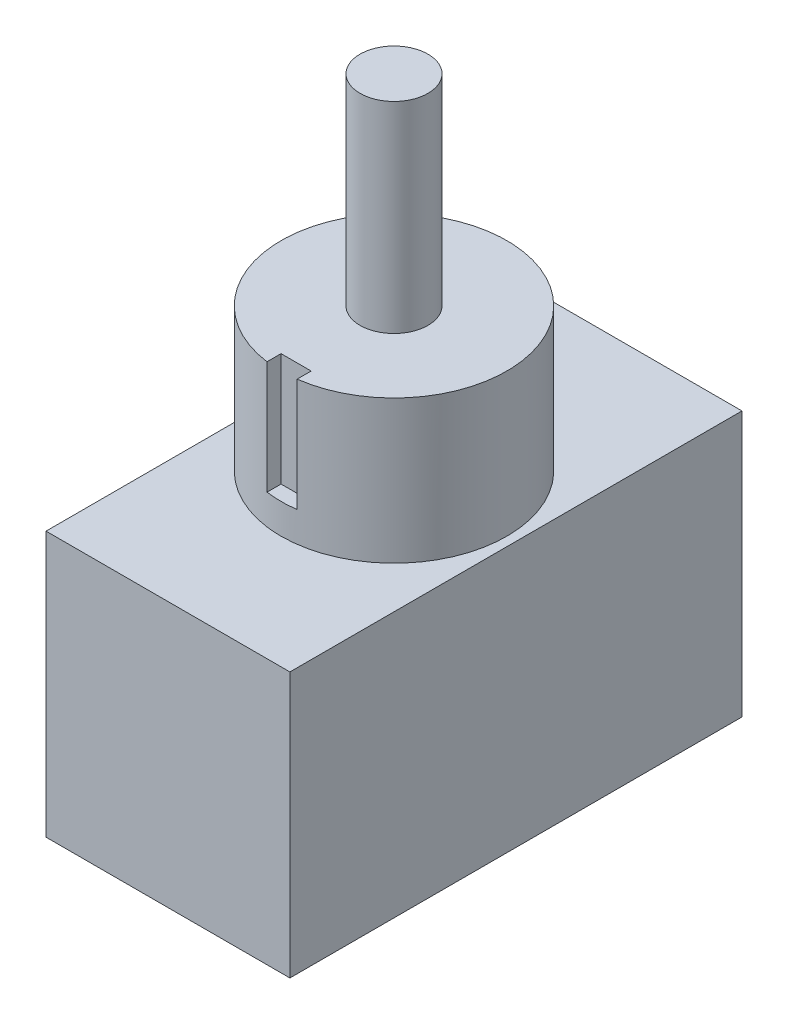
from build123d import *

# Parameters (mm, degrees)
SKETCH1_W           = 12.8524
SKETCH1_H           = 23.8252
BOSS_EXTRUDE1_DEPTH = 13.97
SKETCH2_R           = 5.953125
BOSS_EXTRUDE2_DEPTH = 7.540625
SKETCH3_W           = 1.5875
SKETCH3_H           = 0.79375
CUT_EXTRUDE1_DEPTH  = 5.953125
SKETCH4_R           = 1.790559095
BOSS_EXTRUDE3_DEPTH = 10.5918


with BuildPart() as part:
    # Sketch1 → Boss-Extrude1 (new body)
    with BuildSketch(Plane(origin=(0, 0, 0), x_dir=(1, 0, 0), z_dir=(0, 1, 0))):
        with Locations((-8.41333272, -1.665416216)):
            Rectangle(SKETCH1_W, SKETCH1_H)
    extrude(amount=BOSS_EXTRUDE1_DEPTH)

    # Sketch2 → Boss-Extrude2 (add)
    with BuildSketch(Plane(origin=(0, 13.97, 0), x_dir=(1, 0, 0), z_dir=(0, 1, 0))):
        with Locations((-8.41333272, -1.665416216)):
            Circle(SKETCH2_R)
    extrude(amount=BOSS_EXTRUDE2_DEPTH)

    # Sketch3 → Cut-Extrude1 (cut)
    with BuildSketch(Plane(origin=(0, 21.510625, 0), x_dir=(1, 0, 0), z_dir=(0, 1, 0))):
        with Locations((-8.41333272, -7.221666216)):
            Rectangle(SKETCH3_W, SKETCH3_H)
    extrude(amount=-CUT_EXTRUDE1_DEPTH, mode=Mode.SUBTRACT)

    # Sketch4 → Boss-Extrude3 (add)
    with BuildSketch(Plane(origin=(0, 21.510625, 0), x_dir=(1, 0, 0), z_dir=(0, 1, 0))):
        with Locations((-8.41333272, -1.665416216)):
            Circle(SKETCH4_R)
    extrude(amount=BOSS_EXTRUDE3_DEPTH)


solid = part.part
